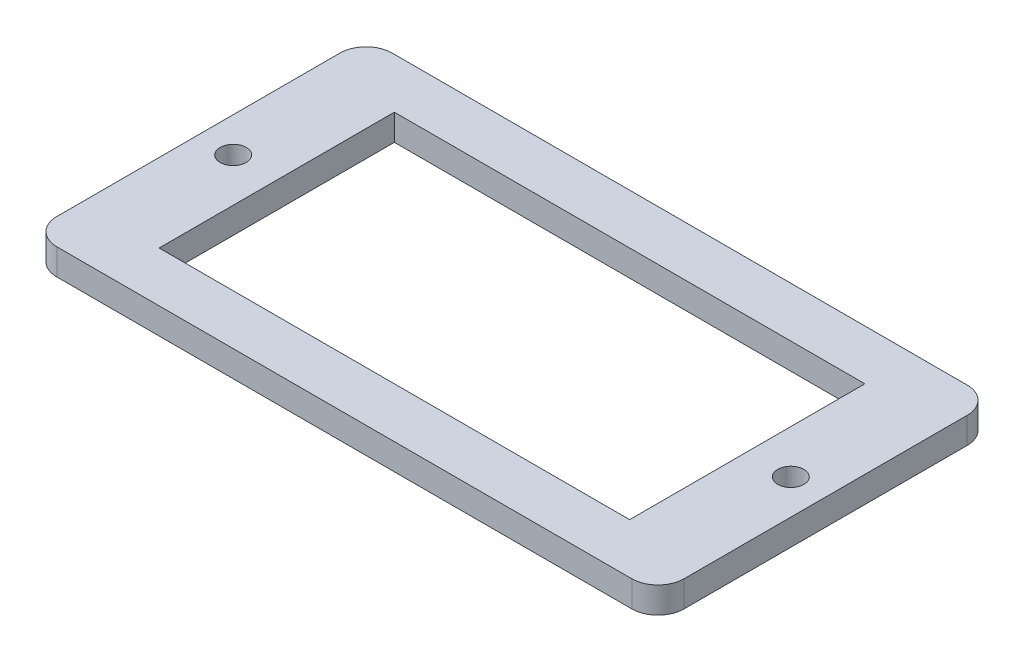
from build123d import *

# Parameters (mm, degrees)
SKETCH1_W           = 72
SKETCH1_H           = 38.5
SKETCH1_R           = 1.5
SKETCH1_W_2         = 54
SKETCH1_H_2         = 27
BOSS_EXTRUDE1_DEPTH = 3
FILLET1_R           = 3


with BuildPart() as part:
    # Sketch1 → Boss-Extrude1 (new body)
    with BuildSketch(Plane(origin=(0, 0, 0), x_dir=(1, 0, 0), z_dir=(0, 1, 0))):
        Rectangle(SKETCH1_W, SKETCH1_H)
        with Locations((-32, 0)):
            Circle(SKETCH1_R, mode=Mode.SUBTRACT)
        with Locations((32, 0)):
            Circle(SKETCH1_R, mode=Mode.SUBTRACT)
        Rectangle(SKETCH1_W_2, SKETCH1_H_2, mode=Mode.SUBTRACT)
    extrude(amount=BOSS_EXTRUDE1_DEPTH)

    # Fillet1
    fillet1_edges = [part.edges().sort_by_distance(p)[0] for p in [
        (-36, 1.5, -19.25),
        (36, 1.5, -19.25),
        (36, 1.5, 19.25),
        (-36, 1.5, 19.25),
    ]]
    fillet(fillet1_edges, radius=FILLET1_R)


solid = part.part
